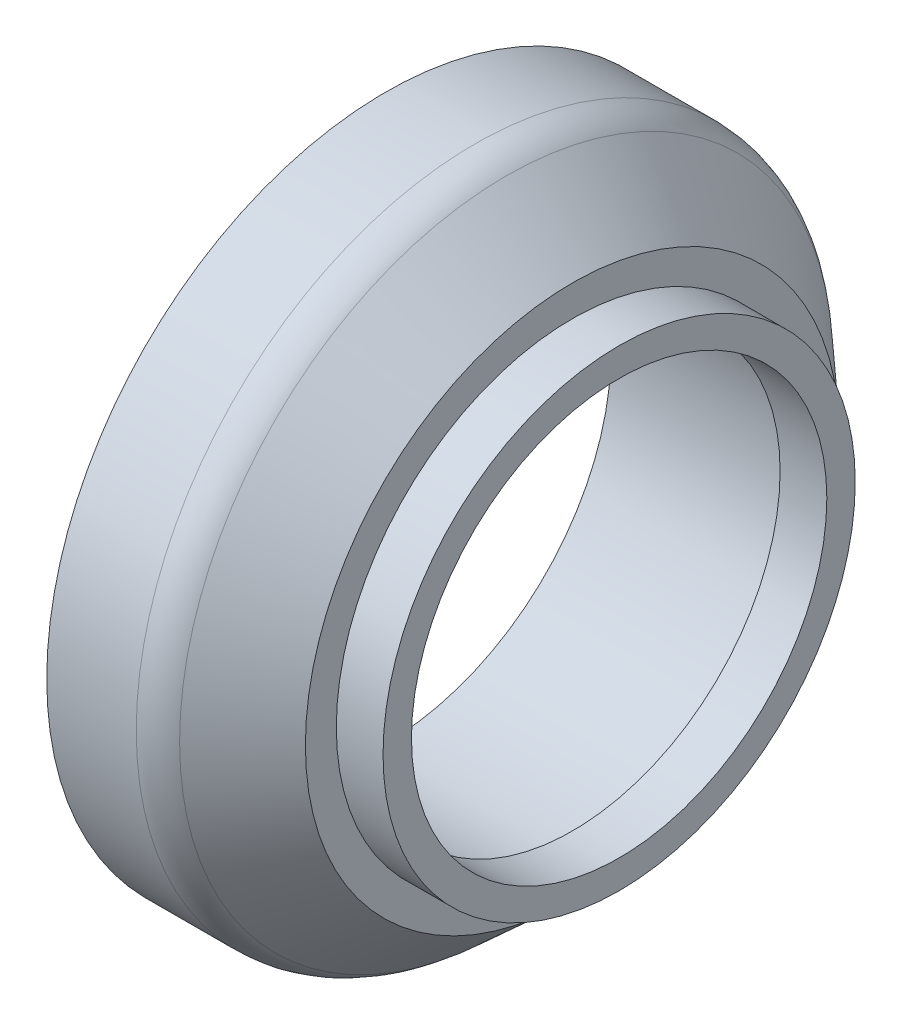
from build123d import *

# Parameters (mm, degrees)
FILLET1_R                    = 10
SKETCH2_R                    = 50.53
SKETCH2_R_2                  = 44.45
BOSS_EXTRUDE1_DEPTH          = 10
SKETCH3_R                    = 5.35
CUT_EXTRUDE1_DEPTH           = 19.4
CHAMFER1_SIZE                = 1
CIRPATTERN1_COUNT            = 12
CHAMFER1_OF_CIRPATTERN1_SIZE = 1


with BuildPart() as part:
    # Sketch1 → Revolve1 (revolve)
    with BuildSketch(Plane.XY):
        Polygon((0, 48.25), (40, 48.25), (40, 57.15), (23, 72.5), (0, 72.5), align=None)
    revolve(axis=Axis((0, 0, 0), (1, 0, 0)))

    # Fillet1
    fillet1_edges = [part.edges().sort_by_distance(p)[0] for p in [
        (23, -72.5, 0),
    ]]
    fillet(fillet1_edges, radius=FILLET1_R)

    # Sketch2 → Boss-Extrude1 (add)
    with BuildSketch(Plane(origin=(40, 0, 0), x_dir=(0, 0, -1), z_dir=(1, 0, 0))):
        Circle(SKETCH2_R)
        Circle(SKETCH2_R_2, mode=Mode.SUBTRACT)
    extrude(amount=BOSS_EXTRUDE1_DEPTH)

    # Sketch3 → Cut-Extrude1 (cut)
    with BuildSketch(Plane.ZY):
        with Locations((-1.718407093, 62.47637215)):
            Circle(SKETCH3_R)
    cut_extrude1 = extrude(amount=-CUT_EXTRUDE1_DEPTH, mode=Mode.SUBTRACT)

    # Chamfer1
    chamfer1_edges = [part.edges().sort_by_distance(p)[0] for p in [
        (0, 62.47637215, -7.068407093),
    ]]
    chamfer(chamfer1_edges, length=CHAMFER1_SIZE)

    # CirPattern1: Cut-Extrude1 ×12 about axis
    cirpattern1_axis = Axis((0, 0, 0), (1, 0, 0))
    for i in range(1, CIRPATTERN1_COUNT):
        add(cut_extrude1.rotate(cirpattern1_axis, i * 360 / CIRPATTERN1_COUNT), mode=Mode.SUBTRACT)

    # Chamfer1 of CirPattern1
    chamfer1_of_cirpattern1_edges = [part.edges().sort_by_distance(p)[0] for p in [
        (0, 57.640328965, 25.116765969),
        (0, 37.359606182, 50.571921872),
        (0, 7.068407093, 62.47637215),
        (0, -25.116765969, 57.640328965),
        (0, -50.571921872, 37.359606182),
        (0, -62.47637215, 7.068407093),
        (0, -57.640328965, -25.116765969),
        (0, -37.359606182, -50.571921872),
        (0, -7.068407093, -62.47637215),
        (0, 25.116765969, -57.640328965),
        (0, 50.571921872, -37.359606182),
    ]]
    chamfer(chamfer1_of_cirpattern1_edges, length=CHAMFER1_OF_CIRPATTERN1_SIZE)


solid = part.part
